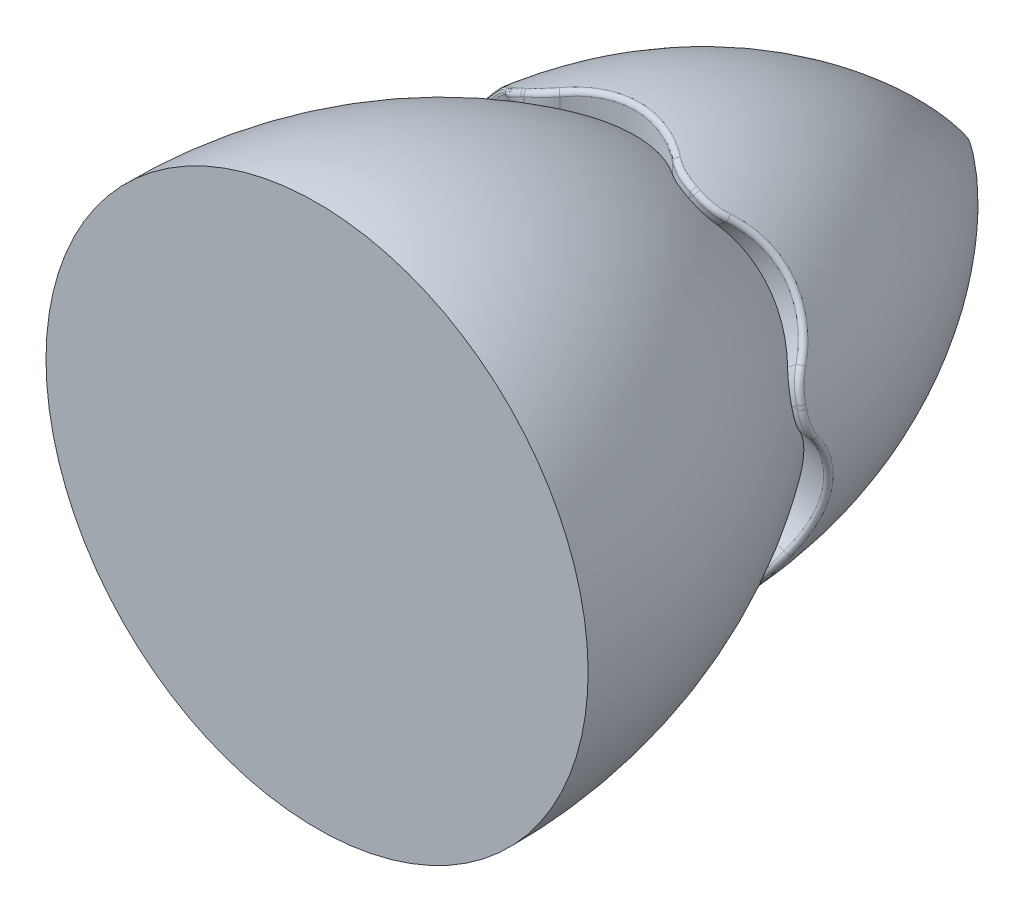
from build123d import *

# Parameters (mm, degrees)
ODEBRAT_VYSUNUT_M1_DEPTH = 46.0000001
KRUHOV_POLE1_COUNT       = 7
ZAOBLIT1_R               = 10
ZAOBLIT2_R               = 1


with BuildPart() as part:
    # Skica1 → Rotovat1 (revolve)
    with BuildSketch(Plane(origin=(0, 0, 0), x_dir=(1, 0, 0), z_dir=(0, 1, 0))):
        with BuildLine():
            Line((0, 0), (45, 0))
            ThreePointArc((45, 0), (31.769079492, 45.8750861), (0, 81.516443683))
            Line((0, 81.516443683), (0, 0))
        make_face()
    revolve(axis=Axis((0, 0, 0), (0, 0, -1)))

    # Skica2 → Odebrat vysunutím1 (cut, through all)
    with BuildSketch(Plane(origin=(0, 0, 0), x_dir=(1, 0, 0), z_dir=(0, 1, 0))):
        with BuildLine():
            Line((15, 0), (-15, 0))
            ThreePointArc((-15, 0), (0, 6.213203436), (15, 0))
        make_face()
    odebrat_vysunut_m1 = extrude(amount=ODEBRAT_VYSUNUT_M1_DEPTH, mode=Mode.SUBTRACT)

    # Kruhové pole1: Odebrat vysunutím1 ×7 about axis
    kruhov_pole1_axis = Axis((0, 0, 0), (0, 0, -1))
    for i in range(1, KRUHOV_POLE1_COUNT):
        add(odebrat_vysunut_m1.rotate(kruhov_pole1_axis, i * 360 / KRUHOV_POLE1_COUNT), mode=Mode.SUBTRACT)

    # Zaoblit1
    zaoblit1_edges = [part.edges().sort_by_distance(p)[0] for p in [
        (-15, 36.78711391, 0),
        (-19.408976776, 34.6638626, 0),
        (-2.446797516, -39.65230046, 0),
        (29.475863553, -26.635788286, 0),
        (39.202598169, 6.438015738, 0),
        (19.408976776, 34.6638626, 0),
        (-38.113670832, 11.208918126, 0),
        (-32.52697015, -22.809821628, 0),
        (-39.202598169, 6.438015738, 0),
        (38.113670832, 11.208918126, 0),
        (32.52697015, -22.809821628, 0),
        (-29.475863553, -26.635788286, 0),
        (2.446797516, -39.65230046, 0),
        (15, 36.78711391, 0),
    ]]
    fillet(zaoblit1_edges, radius=ZAOBLIT1_R)

    # Zaoblit2
    zaoblit2_edges = [part.edges().sort_by_distance(p)[0] for p in [
        (-19.52476826, 40.543599056, 0),
        (-34.762899529, 27.722487297, -6.213203436),
        (-43.871756048, 10.013442028, 0),
        (1e-09, 44.463417385, -6.213203436),
        (19.52476826, 40.543599056, 0),
        (34.762899531, 27.722487295, -6.213203436),
        (43.871756048, 10.013442028, 0),
        (42.958259861, -11.499756038, -6.148754929),
        (35.182416711, -28.057041084, 0),
        (19.291953788, -40.060154825, -6.213203436),
        (0, -45, 0),
        (-19.29195379, -40.060154824, -6.213203436),
        (-35.182416711, -28.057041084, 0),
        (-43.34862668, -9.894041162, -6.213203436),
        (-42.700883857, 14.1069426, -0.490775873),
        (-44.592939999, 5.817302972, -0.490775896),
        (-37.652817462, -24.589360482, -0.490775872),
        (-32.351393984, -31.237135256, -0.490775872),
        (-4.25141154, -44.76937359, -0.490775872),
        (4.251411598, -44.769373583, -0.49077589),
        (32.351393984, -31.237135256, -0.490775872),
        (37.652817462, -24.589360482, -0.490775873),
        (44.59293999, 5.817303047, -0.490775873),
        (42.700883834, 14.106942665, -0.490775894),
        (23.255092653, 38.491193504, -0.490775873),
        (15.594313704, 42.180430198, -0.490775894),
        (-15.594313769, 42.180430176, -0.490775873),
        (-23.255092711, 38.491193468, -0.490775894),
    ]]
    fillet(zaoblit2_edges, radius=ZAOBLIT2_R)

    # Skica3 → Rotovat2 (revolve)
    with BuildSketch(Plane(origin=(0, 0, 0), x_dir=(1, 0, 0), z_dir=(0, 1, 0)), mode=Mode.PRIVATE) as rotovat2_sk:
        with BuildLine():
            Line((0, 41.166879821), (0, -65.488373681))
            Line((0, -65.488373681), (-61.146926861, -65.488373681))
            ThreePointArc((-61.146926861, -65.488373681), (-44.953153196, -3.916672592), (0, 41.166879821))
        make_face()
    revolve(rotovat2_sk.sketch.rotate(Axis((0, 0, -41.166879821), (0, 0, 1)), 185.035500433), axis=Axis((0, 0, -41.166879821), (0, 0, 1)))  # turned: the seam where the file's is


solid = part.part
